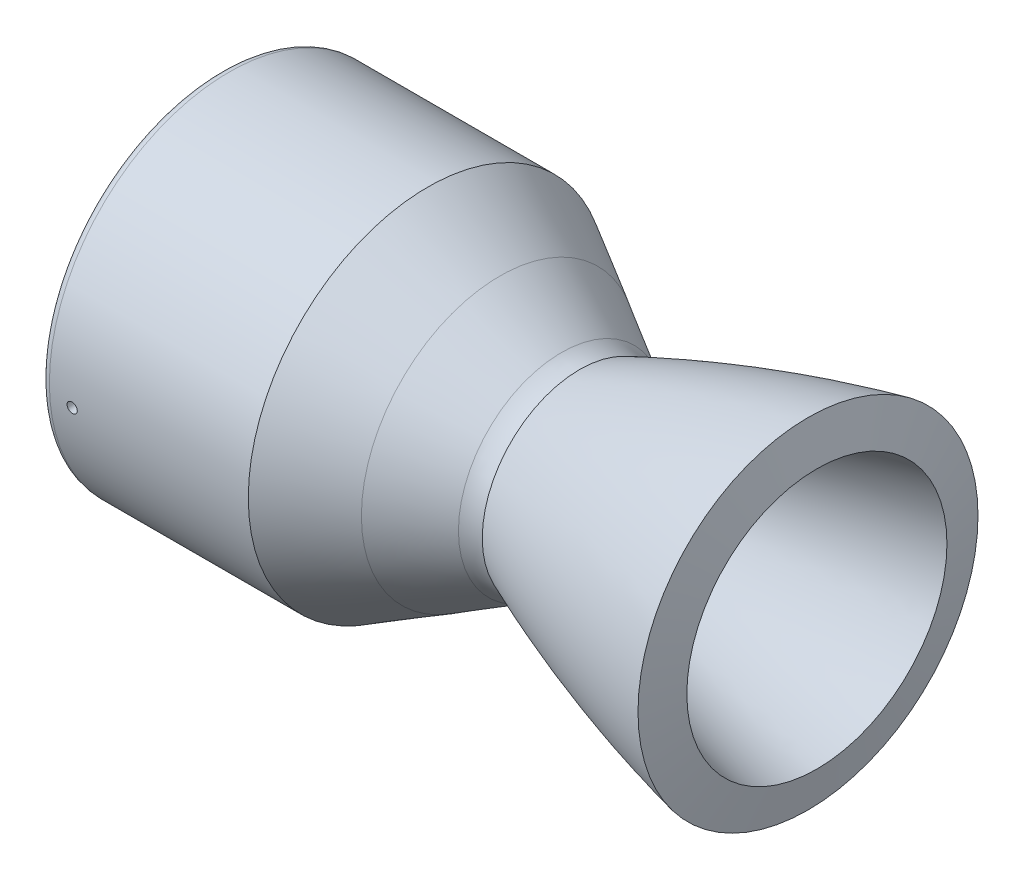
from build123d import *

# Parameters (mm, degrees)
FILLET1_R               = 2.54
CUT_EXTRUDE1_REACH      = 170.913
CUT_EXTRUDE1_END_RADIUS = 43.0260506
SKETCH2_R               = 1.5875
CUT_EXTRUDE2_REACH      = 170.913
CUT_EXTRUDE2_END_RADIUS = 43.0260506
SKETCH3_R               = 5.207


with BuildPart() as part:
    # Model → Revolve1 (revolve)
    with BuildSketch(Plane.XY, mode=Mode.PRIVATE) as revolve1_sk:
        with BuildLine():
            Line((-112.522, 43.0260506), (-73.383883216, 43.0260506))
            ThreePointArc((-73.383883216, 43.0260506), (-52.084113896, 40.221883155), (-32.235888265, 32.000480144))
            Line((-32.235888265, 32.000480144), (-13.143390216, 20.97742306))
            ThreePointArc((-13.143390216, 20.97742306), (-6.833614784, 18.363828893), (-0.062391821, 17.4723806))
            Line((-0.062391821, 17.4723806), (-0.049911, 17.4723806))
            ThreePointArc((-0.049911, 17.4723806), (1.272148929, 17.604626372), (2.541818849, 17.996123109))
            add(Edge.make_bspline(
                [(2.541818849, 17.996123109), (36.7084102, 32.3929756), (72.4744296, 40.360473)],
                knots=[0, 0, 0, 1, 1, 1], degree=2))
            Line((72.4744296, 40.360473), (69.712974983, 52.756616287))
            add(Edge.make_bspline(
                [(-1.156547602, 30.216919323), (4.596059921, 32.619985433), (16.22720374, 37.184585521), (39.705039846, 45.226383183), (57.634347708, 50.065893836), (69.712974983, 52.756616287)],
                knots=[0.017508698, 0.017508698, 0.017508698, 0.017508698, 0.263131524, 0.508754349, 1, 1, 1, 1], degree=3))
            ThreePointArc((-1.156547602, 30.216919323), (-4.072604577, 30.78355815), (-6.793390995, 31.975946137))
            Line((-6.793390995, 31.975946137), (-25.885889044, 42.999003222))
            Line((-25.885889044, 42.999003222), (-48.255103535, 55.7260506))
            Line((-48.255103535, 55.7260506), (-112.522, 55.7260506))
            Line((-112.522, 55.7260506), (-112.522, 43.0260506))
        make_face()
    revolve(revolve1_sk.sketch.rotate(Axis((-112.522, 0, 0), (1, 0, 0)), 90), axis=Axis((-112.522, 0, 0), (1, 0, 0)))

    # Fillet1
    fillet1_edges = [part.edges().sort_by_distance(p)[0] for p in [
        (-112.522, 0, -55.7260506),
    ]]
    fillet(fillet1_edges, radius=FILLET1_R)

    # Cut-Extrude1: up to this cylinder (the profile starts outside it)
    cut_extrude1_end = Plane(origin=(-102.997, 0, 0), z_dir=(-1, 0, 0)) * Cylinder(CUT_EXTRUDE1_END_RADIUS, 428.8781012, mode=Mode.PRIVATE)
    # Sketch2 → Cut-Extrude1 (cut, up to the surface)
    with BuildSketch(Plane(origin=(0, -3.172071011, 55.635696104), x_dir=(-1, 0, 0), z_dir=(0, -0.056922587846044495, 0.9983785950193993)), mode=Mode.PRIVATE) as cut_extrude1_sk1:
        with Locations(Location((102.997, 0, 0), (0, 0, 90))):
            Circle(SKETCH2_R)
    cut_extrude1_tool1 = extrude(cut_extrude1_sk1.sketch, amount=-CUT_EXTRUDE1_REACH, mode=Mode.PRIVATE) - cut_extrude1_end
    add(cut_extrude1_tool1.solids().sort_by_distance((-102.997, -3.172071, 55.635696))[0], mode=Mode.SUBTRACT)

    # Cut-Extrude2: up to this cylinder (the profile starts outside it)
    cut_extrude2_end = Plane(origin=(-106.172, 0, 0), z_dir=(-1, 0, 0)) * Cylinder(CUT_EXTRUDE2_END_RADIUS, 428.8781012, mode=Mode.PRIVATE)
    # Sketch3 → Cut-Extrude2 (cut, up to the surface)
    with BuildSketch(Plane(origin=(0, -55.635696104, -3.172071011), x_dir=(-1, 0, 0), z_dir=(0, -0.9983785950193991, -0.05692258784604798)), mode=Mode.PRIVATE) as cut_extrude2_sk1:
        with Locations(Location((106.172, 0, 0), (0, 0, 90))):
            Circle(SKETCH3_R)
    cut_extrude2_tool1 = extrude(cut_extrude2_sk1.sketch, amount=-CUT_EXTRUDE2_REACH, mode=Mode.PRIVATE) - cut_extrude2_end
    add(cut_extrude2_tool1.solids().sort_by_distance((-106.172, -55.635696, -3.172071))[0], mode=Mode.SUBTRACT)


solid = part.part
